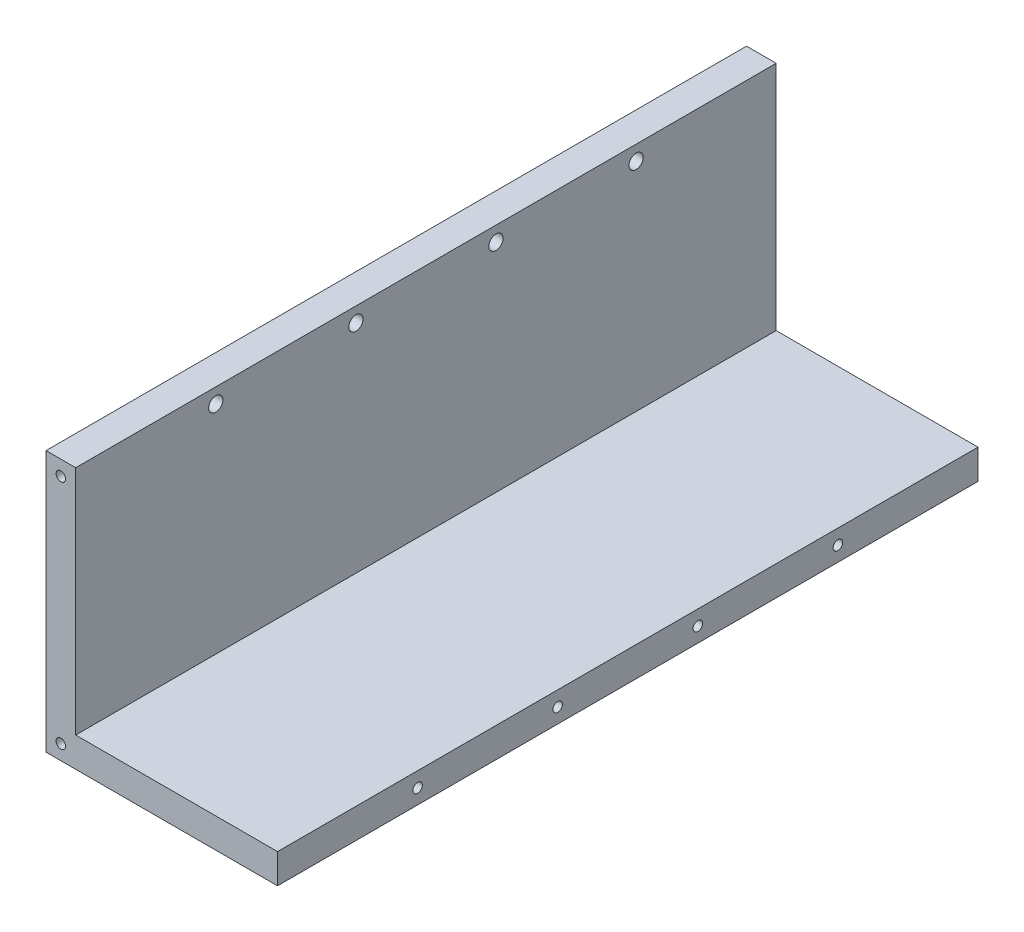
from build123d import *

# Parameters (mm, degrees)
BOSS_EXTRUDE_EQUERRE_DEPTH                     = 118
FRAISAGE_POUR_VIS_T_TE_FRAIS_E_M20_D           = 2.4
FRAISAGE_POUR_VIS_T_TE_FRAIS_E_M20_DEPTH       = 5
FRAISAGE_POUR_VIS_T_TE_FRAIS_E_M20_CSINK_D     = 4.4
FRAISAGE_POUR_VIS_T_TE_FRAIS_E_M20_CSINK_ANGLE = 90
FRAISAGE_POUR_VIS_T_TE_FRAIS_E_M20_TIP         = 0.721032743
TROU_TARAUD_M2X0_43_D                          = 1.6
TROU_TARAUD_M2X0_43_DEPTH                      = 8
TROU_TARAUD_M2X0_43_TIP                        = 0.480688495
TROU_TARAUD_M2X0_44_AT_2_COUNT                 = 2
TROU_TARAUD_M2X0_44_AT_2_PITCH                 = 39


with BuildPart() as part:
    # Esquisse1 → Boss_Extrude_Equerre (new body)
    with BuildSketch(Plane(origin=(0, 0, 0), x_dir=(0, 1, 0), z_dir=(0, 0, 1))):
        Polygon((0, 0), (39, 0), (39, 5), (-5, 5), (-5, 0), (-5, -34), (0, -34), align=None)
    extrude(amount=BOSS_EXTRUDE_EQUERRE_DEPTH)

    # Fraisage pour vis à tête fraisée M20
    with Locations(Plane.ZY.offset(5)):
        with Locations((70.8, 36.5), (94.4, 36.5), (47.2, 36.5), (23.6, 36.5)):
            CounterSinkHole(FRAISAGE_POUR_VIS_T_TE_FRAIS_E_M20_D / 2, FRAISAGE_POUR_VIS_T_TE_FRAIS_E_M20_CSINK_D / 2, depth=FRAISAGE_POUR_VIS_T_TE_FRAIS_E_M20_DEPTH, counter_sink_angle=FRAISAGE_POUR_VIS_T_TE_FRAIS_E_M20_CSINK_ANGLE)
            with Locations((0, 0, -(FRAISAGE_POUR_VIS_T_TE_FRAIS_E_M20_DEPTH + FRAISAGE_POUR_VIS_T_TE_FRAIS_E_M20_TIP / 2))):  # 118° drill point
                Cone(0, FRAISAGE_POUR_VIS_T_TE_FRAIS_E_M20_D / 2, FRAISAGE_POUR_VIS_T_TE_FRAIS_E_M20_TIP, mode=Mode.SUBTRACT)

    # Trou taraudé M2x0.43
    with Locations(Plane.YZ.offset(34)):
        with Locations((-2.5, 70.8), (-2.5, 94.4), (-2.5, 47.2), (-2.5, 23.6)):
            Hole(TROU_TARAUD_M2X0_43_D / 2, depth=TROU_TARAUD_M2X0_43_DEPTH)
            with Locations((0, 0, -(TROU_TARAUD_M2X0_43_DEPTH + TROU_TARAUD_M2X0_43_TIP / 2))):  # 118° drill point
                Cone(0, TROU_TARAUD_M2X0_43_D / 2, TROU_TARAUD_M2X0_43_TIP, mode=Mode.SUBTRACT)

    # Esquisse11 → Trou taraudé M2x0.44 (revolve, cut)
    with BuildSketch(Plane(origin=(-2.5, 36.5, 118), x_dir=(0, -1, 0), z_dir=(1, 0, 0))):
        Polygon((0, 0), (0, 8.480688495), (0.8, 8), (0.8, 0), align=None)
    trou_taraud_m2x0_44 = revolve(axis=Axis((-2.5, 36.5, 124.35), (0, 0, -1)), mode=Mode.SUBTRACT)

    # Trou taraudé M2x0.44 at 2: Trou taraudé M2x0.44 ×2
    with Locations(*[(0, -i * TROU_TARAUD_M2X0_44_AT_2_PITCH, 0) for i in range(1, TROU_TARAUD_M2X0_44_AT_2_COUNT)]):
        add(trou_taraud_m2x0_44, mode=Mode.SUBTRACT)

    # Symétrie1: Trou taraudé M2x0.44 across plane
    add(trou_taraud_m2x0_44.mirror(Plane.XY.offset(59)), mode=Mode.SUBTRACT)

    # Symétrie1 copy 1 sketch → Symétrie1 copy 1 (revolve, cut)
    with BuildSketch(Plane(origin=(-2.5, -2.5, 0), x_dir=(0, -1, 0), z_dir=(1, 0, 0))):
        Polygon((0, 0), (0, -8.480688495), (0.8, -8), (0.8, 0), align=None)
    revolve(axis=Axis((-2.5, -2.5, -6.35), (0, 0, -1)), mode=Mode.SUBTRACT)


solid = part.part
